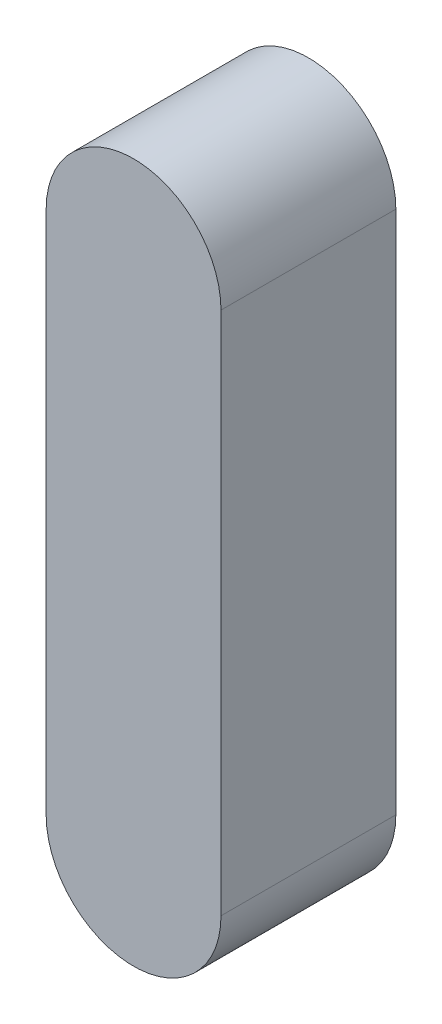
from build123d import *

# Parameters (mm, degrees)
P_IDAT_VYSUNUT_M1_DEPTH = 5


with BuildPart() as part:
    # Skica1 → Přidat vysunutím1 (new body)
    with BuildSketch(Plane.XY):
        with BuildLine():
            Line((-2.5, 0), (-2.5, 15))
            ThreePointArc((-2.5, 15), (0, 17.5), (2.5, 15))
            Line((2.5, 15), (2.5, 0))
            ThreePointArc((2.5, 0), (0, -2.5), (-2.5, 0))
        make_face()
    extrude(amount=P_IDAT_VYSUNUT_M1_DEPTH)


solid = part.part
